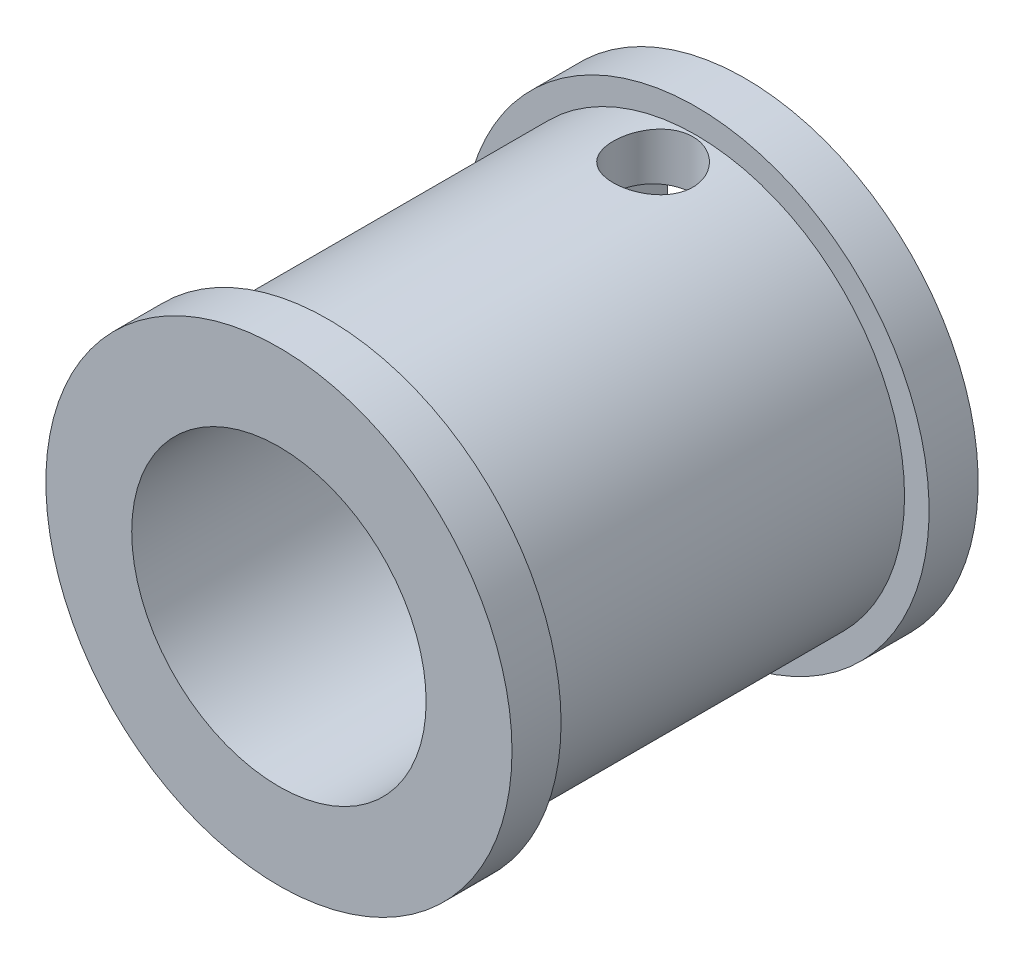
from build123d import *

# Parameters (mm, degrees)
CROQUIS1_R                 = 8.5
SALIENTE_EXTRUIR1_DEPTH    = 19
CROQUIS2_R                 = 1.625
CORTAR_EXTRUIR1_DEPTH      = 1
CORTAR_EXTRUIR1_DEPTH_BACK = 20
CROQUIS3_W                 = 6.34
CROQUIS3_H                 = 3
CORTAR_EXTRUIR2_DEPTH      = 7.5
CROQUIS4_R                 = 9.5
CROQUIS4_R_2               = 8.5
SALIENTE_EXTRUIR2_DEPTH    = 2
CROQUIS5_R                 = 9.5
CROQUIS5_R_2               = 8.5
SALIENTE_EXTRUIR3_DEPTH    = 2
CROQUIS7_R                 = 1.625
CORTAR_EXTRUIR4_DEPTH      = 6.7
CORTAR_EXTRUIR4_DEPTH_BACK = 3
CROQUIS9_R                 = 6
CORTAR_EXTRUIR5_DEPTH      = 9


with BuildPart() as part:
    # Croquis1 → Saliente-Extruir1 (new body)
    with BuildSketch(Plane.XY):
        Circle(CROQUIS1_R)
    extrude(amount=SALIENTE_EXTRUIR1_DEPTH)

    # Croquis2 → Cortar-Extruir1 (cut, two sides)
    with BuildSketch(Plane(origin=(0, 0, 0), x_dir=(-1, 0, 0), z_dir=(0, 0, -1))) as cortar_extruir1_sk:
        Circle(CROQUIS2_R)
    extrude(amount=CORTAR_EXTRUIR1_DEPTH, mode=Mode.SUBTRACT)
    extrude(cortar_extruir1_sk.sketch, amount=-CORTAR_EXTRUIR1_DEPTH_BACK, mode=Mode.SUBTRACT)

    # Croquis3 → Cortar-Extruir2 (cut)
    with BuildSketch(Plane(origin=(0, 0, 0), x_dir=(-1, 0, 0), z_dir=(0, 0, -1))):
        with Locations((0, 5)):
            Rectangle(CROQUIS3_W, CROQUIS3_H)
    extrude(amount=-CORTAR_EXTRUIR2_DEPTH, mode=Mode.SUBTRACT)

    # Croquis4 → Saliente-Extruir2 (add)
    with BuildSketch(Plane(origin=(0, 0, 0), x_dir=(-1, 0, 0), z_dir=(0, 0, -1))):
        Circle(CROQUIS4_R)
        Circle(CROQUIS4_R_2, mode=Mode.SUBTRACT)
    extrude(amount=-SALIENTE_EXTRUIR2_DEPTH)

    # Croquis5 → Saliente-Extruir3 (add)
    with BuildSketch(Plane.XY.offset(19)):
        Circle(CROQUIS5_R)
        Circle(CROQUIS5_R_2, mode=Mode.SUBTRACT)
    extrude(amount=-SALIENTE_EXTRUIR3_DEPTH)

    # Croquis7 → Cortar-Extruir4 (cut, two sides)
    with BuildSketch(Plane.XZ.offset(-6.5)) as cortar_extruir4_sk:
        with Locations((0, 3.75)):
            Circle(CROQUIS7_R)
    extrude(amount=CORTAR_EXTRUIR4_DEPTH, mode=Mode.SUBTRACT)
    extrude(cortar_extruir4_sk.sketch, amount=-CORTAR_EXTRUIR4_DEPTH_BACK, mode=Mode.SUBTRACT)

    # Croquis9 → Cortar-Extruir5 (cut)
    with BuildSketch(Plane.XY.offset(19)):
        Circle(CROQUIS9_R)
    extrude(amount=-CORTAR_EXTRUIR5_DEPTH, mode=Mode.SUBTRACT)


solid = part.part
